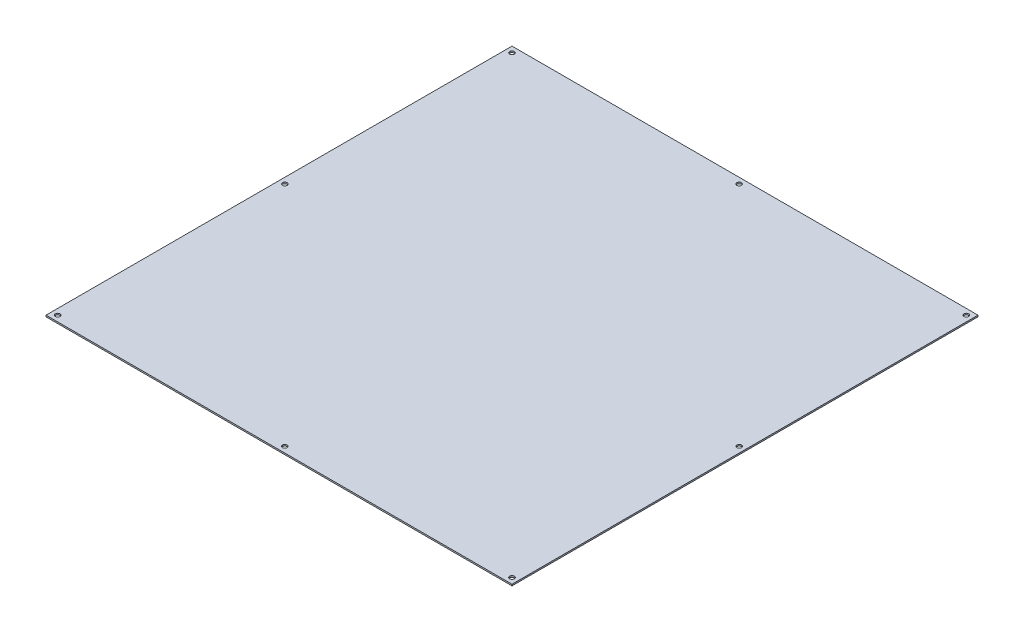
from build123d import *

# Parameters (mm, degrees)
MAIN_PLATE_W        = 320
MAIN_PLATE_H        = 320
BOSS_EXTRUDE1_DEPTH = 1.016
MAIN_HOLES_R        = 1.6
CUT_EXTRUDE1_DEPTH  = 2.016


with BuildPart() as part:
    # main_plate → Boss-Extrude1 (new body)
    with BuildSketch(Plane(origin=(0, 0, 0), x_dir=(1, 0, 0), z_dir=(0, 1, 0))):
        Rectangle(MAIN_PLATE_W, MAIN_PLATE_H)
    extrude(amount=BOSS_EXTRUDE1_DEPTH)

    # main_holes → Cut-Extrude1 (cut, through all)
    with BuildSketch(Plane(origin=(0, 1.016, 0), x_dir=(1, 0, 0), z_dir=(0, 1, 0))):
        with Locations((-156, 156)):
            Circle(MAIN_HOLES_R)
        with Locations((0, 156)):
            Circle(MAIN_HOLES_R)
        with Locations((156, 156)):
            Circle(MAIN_HOLES_R)
        with Locations((-156, 0)):
            Circle(MAIN_HOLES_R)
        with Locations((156, 0)):
            Circle(MAIN_HOLES_R)
        with Locations((-156, -156)):
            Circle(MAIN_HOLES_R)
        with Locations((0, -156)):
            Circle(MAIN_HOLES_R)
        with Locations((156, -156)):
            Circle(MAIN_HOLES_R)
    extrude(amount=-CUT_EXTRUDE1_DEPTH, mode=Mode.SUBTRACT)


solid = part.part
